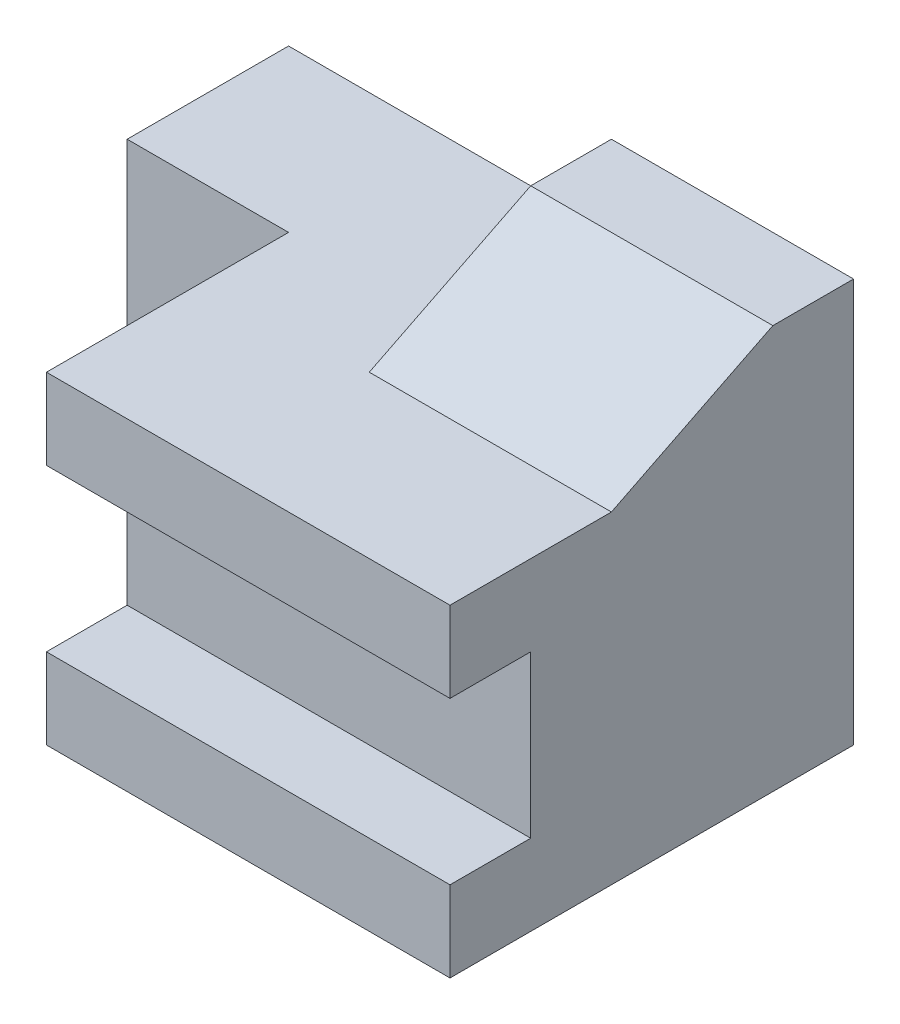
from build123d import *

# Parameters (mm, degrees)
SKETCH1_W           = 70
SKETCH1_H           = 40
BOSS_EXTRUDE1_DEPTH = 50
SKETCH2_W           = 20
SKETCH2_H           = 30
CUT_EXTRUDE1_DEPTH  = 50
SKETCH3_W           = 10
SKETCH3_H           = 20
CUT_EXTRUDE2_DEPTH  = 50
SKETCH4_W           = 30
SKETCH4_H           = 30
BOSS_EXTRUDE2_DEPTH = 10
CUT_EXTRUDE3_DEPTH  = 56


with BuildPart() as part:
    # Sketch1 → Boss-Extrude1 (new body)
    with BuildSketch(Plane.XY):
        with Locations((35, 20)):
            Rectangle(SKETCH1_W, SKETCH1_H)
    extrude(amount=BOSS_EXTRUDE1_DEPTH)

    # Sketch2 → Cut-Extrude1 (cut)
    with BuildSketch(Plane(origin=(0, 40, 0), x_dir=(1, 0, 0), z_dir=(0, 1, 0))):
        with Locations((10, -35)):
            Rectangle(SKETCH2_W, SKETCH2_H)
    extrude(amount=-CUT_EXTRUDE1_DEPTH, mode=Mode.SUBTRACT)

    # Sketch3 → Cut-Extrude2 (cut)
    with BuildSketch(Plane.ZY.offset(-20)):
        with Locations((45, 20)):
            Rectangle(SKETCH3_W, SKETCH3_H)
    extrude(amount=-CUT_EXTRUDE2_DEPTH, mode=Mode.SUBTRACT)

    # Sketch4 → Boss-Extrude2 (add)
    with BuildSketch(Plane(origin=(0, 40, 0), x_dir=(1, 0, 0), z_dir=(0, 1, 0))):
        with Locations((55, -15)):
            Rectangle(SKETCH4_W, SKETCH4_H)
    extrude(amount=BOSS_EXTRUDE2_DEPTH)

    # Sketch5 → Cut-Extrude3 (cut)
    with BuildSketch(Plane.ZY.offset(-40)):
        Polygon((10, 50), (30, 40), (30, 50), align=None)
    extrude(amount=-CUT_EXTRUDE3_DEPTH, mode=Mode.SUBTRACT)


solid = part.part
